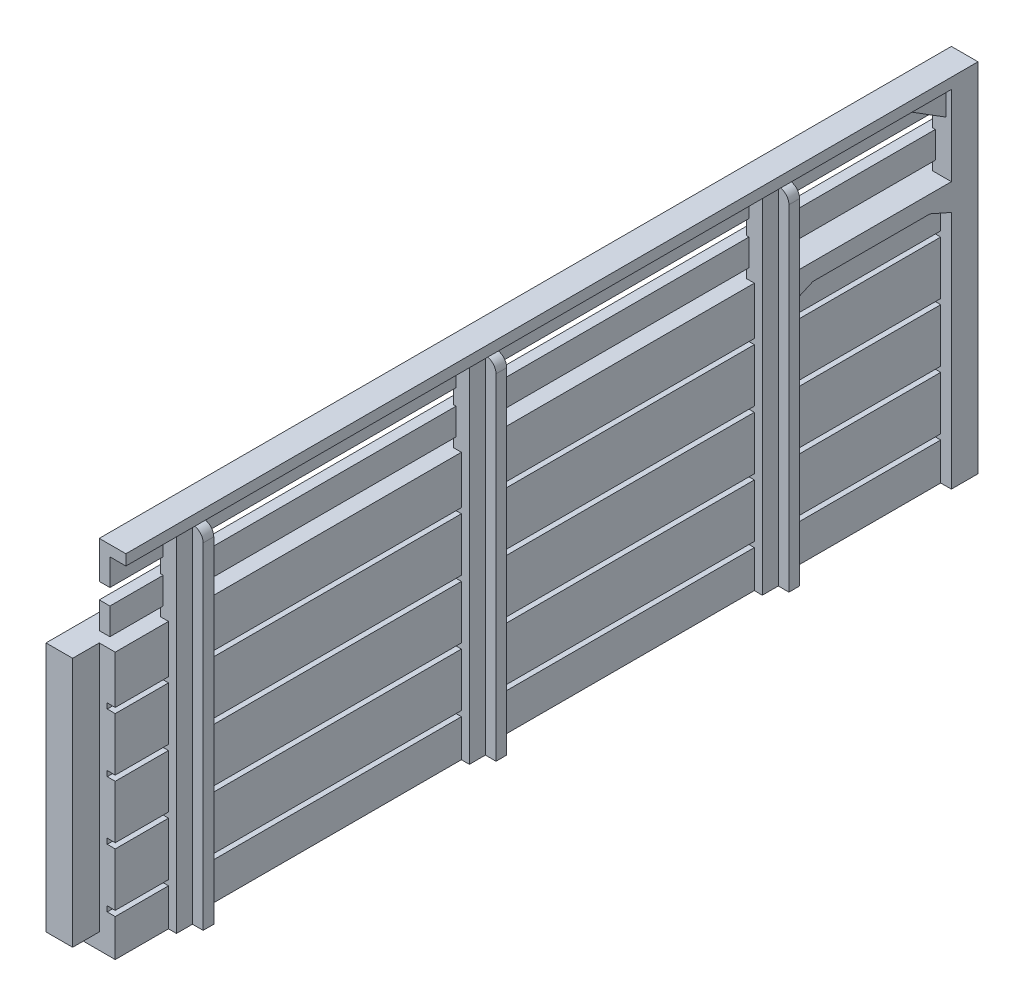
from build123d import *

# Parameters (mm, degrees)
SKETCH1_W            = 160
SKETCH1_H            = 50
BOSS_EXTRUDE1_DEPTH  = 3
SKETCH2_W            = 160
SKETCH2_H            = 1
CUT_EXTRUDE1_DEPTH   = 1.5
SKETCH3_W            = 5
SKETCH3_H            = 65
BOSS_EXTRUDE2_DEPTH  = 1.5
SKETCH4_W            = 2
SKETCH4_H            = 65
BOSS_EXTRUDE3_DEPTH  = 2
FILLET1_R            = 2
SKETCH5_W            = 160
SKETCH5_H            = 5
BOSS_EXTRUDE4_DEPTH  = 2
SKETCH6_W            = 5
SKETCH6_H            = 160
BOSS_EXTRUDE5_DEPTH  = 2
SKETCH9_W            = 5
SKETCH9_H            = 65
BOSS_EXTRUDE8_DEPTH  = 0.5
SKETCH10_W           = 160
SKETCH10_H           = 3
BOSS_EXTRUDE9_DEPTH  = 5
SKETCH11_W           = 5
SKETCH11_H           = 3
BOSS_EXTRUDE10_DEPTH = 47
SKETCH13_W           = 10
SKETCH13_H           = 46.714659276
BOSS_EXTRUDE11_DEPTH = 5
BOSS_EXTRUDE12_DEPTH = 2
BOSS_EXTRUDE13_DEPTH = 2
BOSS_EXTRUDE14_DEPTH = 0.285341


with BuildPart() as part:
    # Sketch1 → Boss-Extrude1 (new body)
    with BuildSketch(Plane(origin=(0, 0, 0), x_dir=(0, 0, -1), z_dir=(1, 0, 0))):
        Rectangle(SKETCH1_W, SKETCH1_H)
    extrude(amount=BOSS_EXTRUDE1_DEPTH)

    # Sketch2 → Cut-Extrude1 (cut)
    with BuildSketch(Plane(origin=(3, 0, 0), x_dir=(0, 0, -1), z_dir=(1, 0, 0))):
        with Locations((0, -17.5)):
            Rectangle(SKETCH2_W, SKETCH2_H)
        with Locations((0, -6.5)):
            Rectangle(SKETCH2_W, SKETCH2_H)
        with Locations((0, 4.5)):
            Rectangle(SKETCH2_W, SKETCH2_H)
        with Locations((0, 15.5)):
            Rectangle(SKETCH2_W, SKETCH2_H)
    extrude(amount=-CUT_EXTRUDE1_DEPTH, mode=Mode.SUBTRACT)

    # Sketch3 → Boss-Extrude2 (add, symmetric)
    with BuildSketch(Plane(origin=(3, 0, 0), x_dir=(0, 0, -1), z_dir=(1, 0, 0))):
        with Locations((77.5, 7.5)):
            Rectangle(SKETCH3_W, SKETCH3_H)
        with Locations((42.5, 7.5)):
            Rectangle(SKETCH3_W, SKETCH3_H)
        with Locations((-12.5, 7.5)):
            Rectangle(SKETCH3_W, SKETCH3_H)
        with Locations((-67.5, 7.5)):
            Rectangle(SKETCH3_W, SKETCH3_H)
    extrude(amount=BOSS_EXTRUDE2_DEPTH, both=True)

    # Sketch4 → Boss-Extrude3 (add)
    with BuildSketch(Plane(origin=(4.5, 0, 0), x_dir=(0, 0, -1), z_dir=(1, 0, 0))):
        with Locations((44, 7.5)):
            Rectangle(SKETCH4_W, SKETCH4_H)
        with Locations((-11, 7.5)):
            Rectangle(SKETCH4_W, SKETCH4_H)
        with Locations((-66, 7.5)):
            Rectangle(SKETCH4_W, SKETCH4_H)
    extrude(amount=BOSS_EXTRUDE3_DEPTH)

    # Fillet1
    fillet1_edges = [part.edges().sort_by_distance(p)[0] for p in [
        (6.5, 40, -44),
        (6.5, 40, 11),
        (6.5, 40, 66),
    ]]
    fillet(fillet1_edges, radius=FILLET1_R)

    # Sketch5 → Boss-Extrude4 (add)
    with BuildSketch(Plane.ZY):
        with Locations((0, 29.5)):
            Rectangle(SKETCH5_W, SKETCH5_H)
        with Locations((0, 37.5)):
            Rectangle(SKETCH5_W, SKETCH5_H)
    extrude(amount=-BOSS_EXTRUDE4_DEPTH)

    # Sketch6 → Boss-Extrude5 (add)
    with BuildSketch(Plane(origin=(0, 40, 0), x_dir=(1, 0, 0), z_dir=(0, 1, 0))):
        with Locations((2.5, 0)):
            Rectangle(SKETCH6_W, SKETCH6_H)
    extrude(amount=BOSS_EXTRUDE5_DEPTH)

    # Sketch9 → Boss-Extrude8 (add)
    with BuildSketch(Plane(origin=(4.5, 0, 0), x_dir=(0, 0, -1), z_dir=(1, 0, 0))):
        with Locations((77.5, 7.5)):
            Rectangle(SKETCH9_W, SKETCH9_H)
    extrude(amount=BOSS_EXTRUDE8_DEPTH)

    # Sketch10 → Boss-Extrude9 (add)
    with BuildSketch(Plane.ZY):
        with Locations((0, -23.5)):
            Rectangle(SKETCH10_W, SKETCH10_H)
    extrude(amount=BOSS_EXTRUDE9_DEPTH)

    # Sketch11 → Boss-Extrude10 (add)
    with BuildSketch(Plane(origin=(0, -22, 0), x_dir=(1, 0, 0), z_dir=(0, 1, 0))):
        with Locations((-2.5, 78.5)):
            Rectangle(SKETCH11_W, SKETCH11_H)
    extrude(amount=BOSS_EXTRUDE10_DEPTH)

    # Sketch13 → Boss-Extrude11 (add)
    with BuildSketch(Plane.ZY):
        with Locations((80, 1.357329638)):
            Rectangle(SKETCH13_W, SKETCH13_H)
    extrude(amount=BOSS_EXTRUDE11_DEPTH)

    # Sketch14 → Boss-Extrude12 (add)
    with BuildSketch(Plane(origin=(2, 0, 0), x_dir=(0, 0, -1), z_dir=(1, 0, 0))):
        Polygon((75, 40), (75, 35), (67, 40), align=None)
    extrude(amount=BOSS_EXTRUDE12_DEPTH)

    # Sketch15 → Boss-Extrude13 (add)
    with BuildSketch(Plane(origin=(3, 0, 0), x_dir=(0, 0, -1), z_dir=(1, 0, 0))):
        Polygon((75, 25), (45, 25), (45, 20), (49, 21.77425237), (71, 21.77425237), (75, 20), align=None)
    extrude(amount=BOSS_EXTRUDE13_DEPTH)

    # Sketch16 → Boss-Extrude14 (add)
    with BuildSketch(Plane(origin=(0, 24.714659276, 0), x_dir=(1, 0, 0), z_dir=(0, 1, 0))):
        Polygon((0, -75), (-5, -75), (-5, -85), (0, -85), (0, -80), align=None)
    extrude(amount=BOSS_EXTRUDE14_DEPTH)


solid = part.part
